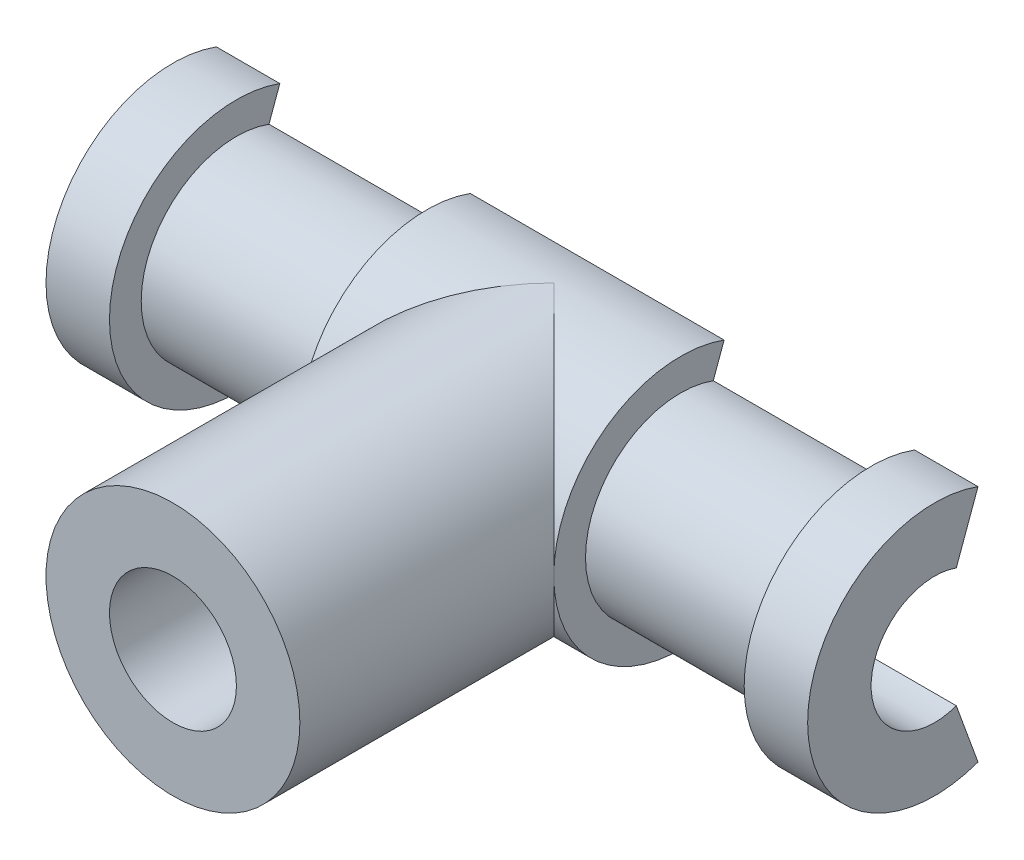
from build123d import *

# Parameters (mm, degrees)
SKETCH1_R           = 3.175
SKETCH1_R_2         = 1.5875
BOSS_EXTRUDE1_DEPTH = 9.525
BOSS_EXTRUDE2_DEPTH = 19.05
SKETCH4_R           = 1.5875
CUT_EXTRUDE1_DEPTH  = 22.533897829
CUT_EXTRUDE2_START  = -7.9375
SKETCH5_R           = 3.175
SKETCH5_R_2         = 2.38125
CUT_EXTRUDE2_DEPTH  = 4.7625


with BuildPart() as part:
    # Sketch1 → Boss-Extrude1 (new body)
    with BuildSketch(Plane.XY):
        Circle(SKETCH1_R)
        Circle(SKETCH1_R_2, mode=Mode.SUBTRACT)
    extrude(amount=BOSS_EXTRUDE1_DEPTH)

    # Sketch3 → Boss-Extrude2 (add)
    with BuildSketch(Plane.ZY.offset(9.525)):
        with BuildLine():
            Line((-1.085913955, -2.983524071), (-0.542956978, -1.491762035))
            ThreePointArc((-0.542956978, -1.491762035), (1.5875, 0), (-0.542956978, 1.491762035))
            Line((-0.542956978, 1.491762035), (-1.085913955, 2.983524071))
            ThreePointArc((-1.085913955, 2.983524071), (3.175, 0), (-1.085913955, -2.983524071))
        make_face()
    extrude(amount=-BOSS_EXTRUDE2_DEPTH)

    # Sketch4 → Cut-Extrude1 (cut, through all)
    with BuildSketch(Plane.ZY.offset(9.525)):
        Circle(SKETCH4_R)
    extrude(amount=-CUT_EXTRUDE1_DEPTH, mode=Mode.SUBTRACT)

    # Sketch5 → Cut-Extrude2 (cut)
    with BuildSketch(Plane(origin=(0, 0, 0), x_dir=(0, 0, -1), z_dir=(1, 0, 0)).offset(CUT_EXTRUDE2_START)):
        Circle(SKETCH5_R)
        Circle(SKETCH5_R_2, mode=Mode.SUBTRACT)
    cut_extrude2 = extrude(amount=CUT_EXTRUDE2_DEPTH, mode=Mode.SUBTRACT)

    # Mirror1: Cut-Extrude2 across plane
    add(cut_extrude2.mirror(Plane(origin=(0, 0, 0), x_dir=(0, 0, 1), z_dir=(1, 0, 0))), mode=Mode.SUBTRACT)


solid = part.part
